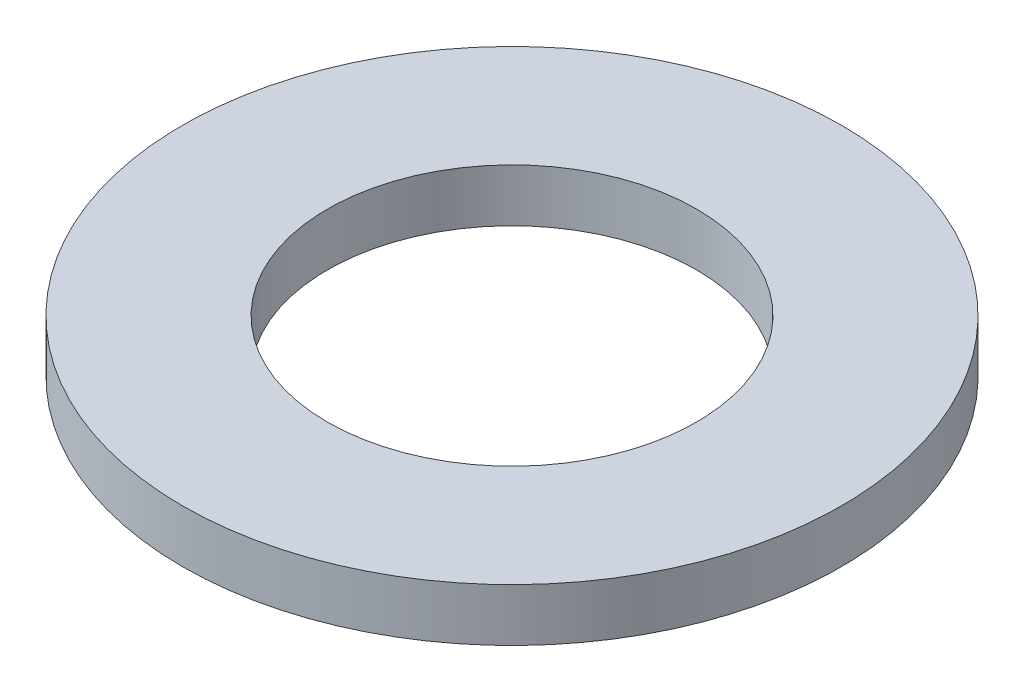
from build123d import *

# Parameters (mm, degrees)
SKETCH1_R           = 12.5
SKETCH1_R_2         = 7
BOSS_EXTRUDE1_DEPTH = 2


with BuildPart() as part:
    # Sketch1 → Boss-Extrude1 (new body)
    with BuildSketch(Plane(origin=(0, 0, 0), x_dir=(1, 0, 0), z_dir=(0, 1, 0))):
        Circle(SKETCH1_R)
        Circle(SKETCH1_R_2, mode=Mode.SUBTRACT)
    extrude(amount=BOSS_EXTRUDE1_DEPTH)


solid = part.part
